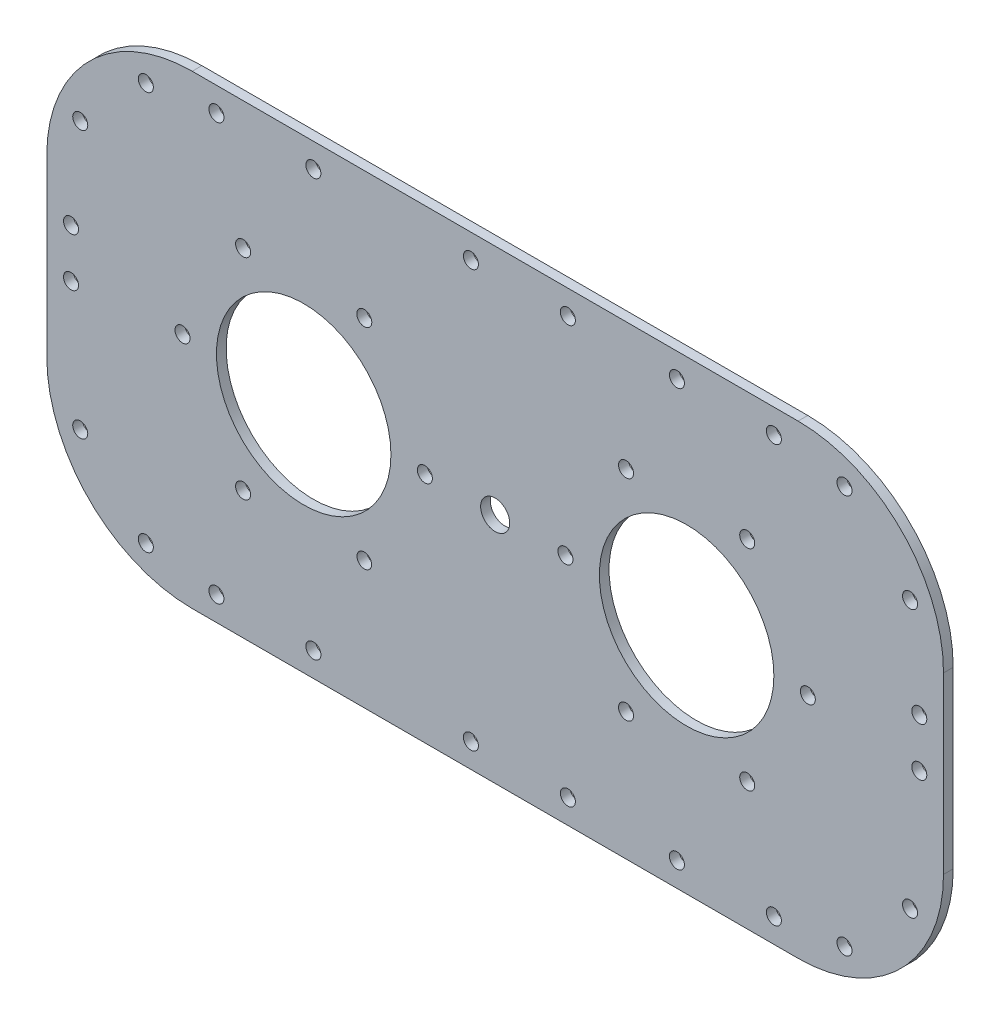
from build123d import *

# Parameters (mm, degrees)
SKETCH_1_R          = 1.55
SKETCH_1_R_2        = 1.51
SKETCH_1_R_3        = 18
EXTRUDE_1_DEPTH     = 2
SKETCH_2_R          = 1.55
SKETCH_2_R_2        = 3
CUT_EXTRUDE_1_DEPTH = 10


with BuildPart() as part:
    # 草图1 → 凸台-拉伸1 (new body)
    with BuildSketch(Plane.XY):
        with BuildLine():
            Line((-62.5, 48), (62.5, 48))
            ThreePointArc((62.5, 48), (83.713203436, 39.213203436), (92.5, 18))
            Line((92.5, 18), (92.5, -18))
            ThreePointArc((92.5, -18), (83.713203436, -39.213203436), (62.5, -48))
            Line((62.5, -48), (-62.5, -48))
            ThreePointArc((-62.5, -48), (-83.713203436, -39.213203436), (-92.5, -18))
            Line((-92.5, -18), (-92.5, 18))
            ThreePointArc((-92.5, 18), (-83.713203436, 39.213203436), (-62.5, 48))
        make_face()
        with Locations((-64.5, 0)):
            Circle(SKETCH_1_R, mode=Mode.SUBTRACT)
        with Locations((-14.5, 0)):
            Circle(SKETCH_1_R, mode=Mode.SUBTRACT)
        with Locations((14.5, 0)):
            Circle(SKETCH_1_R, mode=Mode.SUBTRACT)
        with Locations((64.5, 0)):
            Circle(SKETCH_1_R, mode=Mode.SUBTRACT)
        with Locations((27, 21.650635095)):
            Circle(SKETCH_1_R, mode=Mode.SUBTRACT)
        with Locations((52, 21.650635095)):
            Circle(SKETCH_1_R, mode=Mode.SUBTRACT)
        with Locations((52, -21.650635095)):
            Circle(SKETCH_1_R, mode=Mode.SUBTRACT)
        with Locations((27, -21.650635095)):
            Circle(SKETCH_1_R, mode=Mode.SUBTRACT)
        with Locations((-52, -21.650635095)):
            Circle(SKETCH_1_R, mode=Mode.SUBTRACT)
        with Locations((-52, 21.650635095)):
            Circle(SKETCH_1_R, mode=Mode.SUBTRACT)
        with Locations((-27, -21.650635095)):
            Circle(SKETCH_1_R_2, mode=Mode.SUBTRACT)
        with Locations((-27, 21.650635095)):
            Circle(SKETCH_1_R, mode=Mode.SUBTRACT)
        with Locations((-39.5, 0)):
            Circle(SKETCH_1_R_3, mode=Mode.SUBTRACT)
        with Locations((39.5, 0)):
            Circle(SKETCH_1_R_3, mode=Mode.SUBTRACT)
        with Locations((57.5, -43)):
            Circle(SKETCH_1_R, mode=Mode.SUBTRACT)
        with Locations((37.5, -43)):
            Circle(SKETCH_1_R, mode=Mode.SUBTRACT)
        with Locations((-57.5, -43)):
            Circle(SKETCH_1_R, mode=Mode.SUBTRACT)
        with Locations((-37.5, -43)):
            Circle(SKETCH_1_R, mode=Mode.SUBTRACT)
        with Locations((-57.5, 43)):
            Circle(SKETCH_1_R, mode=Mode.SUBTRACT)
        with Locations((-37.5, 43)):
            Circle(SKETCH_1_R, mode=Mode.SUBTRACT)
        with Locations((37.5, 43)):
            Circle(SKETCH_1_R, mode=Mode.SUBTRACT)
        with Locations((57.5, 43)):
            Circle(SKETCH_1_R, mode=Mode.SUBTRACT)
        with Locations((15, -43)):
            Circle(SKETCH_1_R, mode=Mode.SUBTRACT)
        with Locations((-5, -43)):
            Circle(SKETCH_1_R, mode=Mode.SUBTRACT)
        with Locations((-5, 43)):
            Circle(SKETCH_1_R, mode=Mode.SUBTRACT)
        with Locations((15, 43)):
            Circle(SKETCH_1_R, mode=Mode.SUBTRACT)
        with Locations((85.596988313, 27.567085809)):
            Circle(SKETCH_1_R, mode=Mode.SUBTRACT)
        with Locations((72.067085809, 41.096988313)):
            Circle(SKETCH_1_R, mode=Mode.SUBTRACT)
        with Locations((72.067085809, -41.096988313)):
            Circle(SKETCH_1_R, mode=Mode.SUBTRACT)
        with Locations((85.596988313, -27.567085809)):
            Circle(SKETCH_1_R, mode=Mode.SUBTRACT)
        with Locations((-85.596988313, -27.567085809)):
            Circle(SKETCH_1_R, mode=Mode.SUBTRACT)
        with Locations((-72.067085809, -41.096988313)):
            Circle(SKETCH_1_R, mode=Mode.SUBTRACT)
        with Locations((-85.596988313, 27.567085809)):
            Circle(SKETCH_1_R, mode=Mode.SUBTRACT)
        with Locations((-72.067085809, 41.096988313)):
            Circle(SKETCH_1_R, mode=Mode.SUBTRACT)
    extrude(amount=EXTRUDE_1_DEPTH)

    # 草图2 → 切除-拉伸1 (cut)
    with BuildSketch(Plane.XY.offset(2)):
        with Locations((87.5, 8)):
            Circle(SKETCH_2_R)
        with Locations((87.5, -2)):
            Circle(SKETCH_2_R)
        with Locations((-87.5, 8)):
            Circle(SKETCH_2_R)
        with Locations((-87.5, -2)):
            Circle(SKETCH_2_R)
        Circle(SKETCH_2_R_2)
    extrude(amount=-CUT_EXTRUDE_1_DEPTH, mode=Mode.SUBTRACT)


solid = part.part
